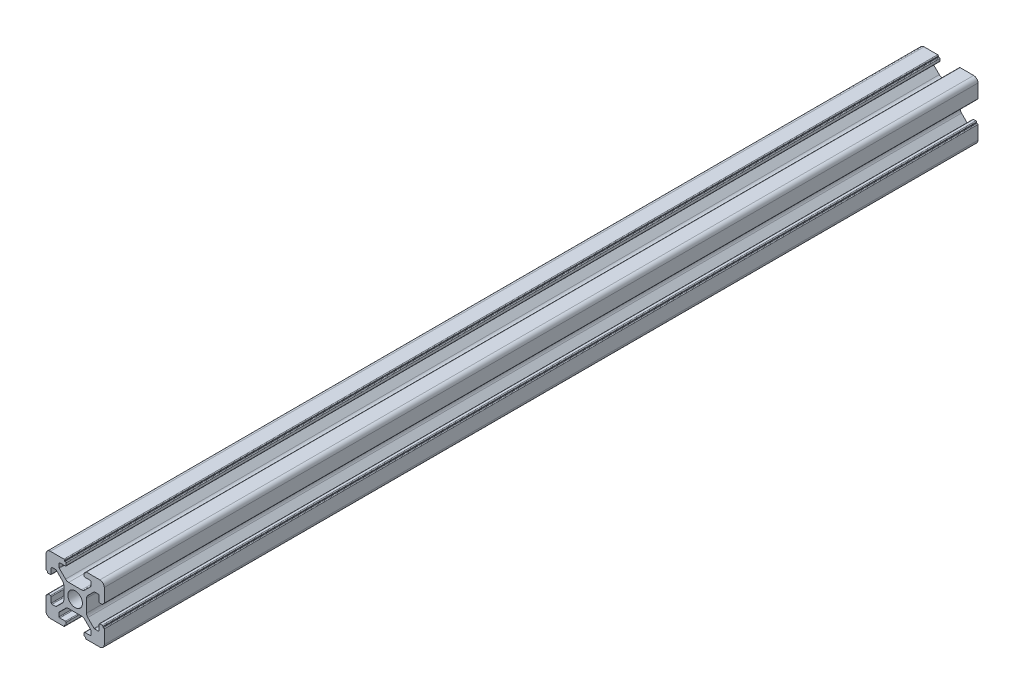
from build123d import *

# Parameters (mm, degrees)
SKETCH_1_R      = 2.5
EXTRUDE_1_DEPTH = 300


with BuildPart() as part:
    # 草图1 → 凸台-拉伸1 (new body)
    with BuildSketch(Plane.XY):
        with BuildLine():
            Line((-8.502261885, -10.002261885), (-3.85, -10.002261885))
            ThreePointArc((-3.85, -10.002261885), (-3.673223305, -9.929038581), (-3.6, -9.752261885))
            Line((-3.6, -9.752261885), (-3.6, -9.502261885))
            Line((-3.6, -9.502261885), (-3.35, -9.502261885))
            ThreePointArc((-3.35, -9.502261885), (-3.173223305, -9.429038581), (-3.1, -9.252261885))
            Line((-3.1, -9.252261885), (-3.1, -8.45))
            ThreePointArc((-3.1, -8.45), (-3.173223305, -8.273223305), (-3.35, -8.2))
            Line((-3.35, -8.2), (-5.25, -8.2))
            ThreePointArc((-5.25, -8.2), (-5.426776695, -8.126776695), (-5.5, -7.95))
            Line((-5.5, -7.95), (-5.5, -6.664213562))
            ThreePointArc((-5.5, -6.664213562), (-5.480969883, -6.568542704), (-5.426776695, -6.487436867))
            Line((-5.426776695, -6.487436867), (-3.278679656, -4.339339828))
            ThreePointArc((-3.278679656, -4.339339828), (-2.792044633, -4.014180701), (-2.218019485, -3.9))
            Line((-2.218019485, -3.9), (2.218019485, -3.9))
            ThreePointArc((2.218019485, -3.9), (2.792044633, -4.014180701), (3.278679656, -4.339339828))
            Line((3.278679656, -4.339339828), (5.426776695, -6.487436867))
            ThreePointArc((5.426776695, -6.487436867), (5.480969883, -6.568542704), (5.5, -6.664213562))
            Line((5.5, -6.664213562), (5.5, -7.95))
            ThreePointArc((5.5, -7.95), (5.426776695, -8.126776695), (5.25, -8.2))
            Line((5.25, -8.2), (3.35, -8.2))
            ThreePointArc((3.35, -8.2), (3.173223305, -8.273223305), (3.1, -8.45))
            Line((3.1, -8.45), (3.1, -9.252261885))
            ThreePointArc((3.1, -9.252261885), (3.173223305, -9.429038581), (3.35, -9.502261885))
            Line((3.35, -9.502261885), (3.6, -9.502261885))
            Line((3.6, -9.502261885), (3.6, -9.752261885))
            ThreePointArc((3.6, -9.752261885), (3.673223305, -9.929038581), (3.85, -10.002261885))
            Line((3.85, -10.002261885), (8.502261885, -10.002261885))
            ThreePointArc((8.502261885, -10.002261885), (9.562922057, -9.562922057), (10.002261885, -8.502261885))
            Line((10.002261885, -8.502261885), (10.002261885, -3.85))
            ThreePointArc((10.002261885, -3.85), (9.929038581, -3.673223305), (9.752261885, -3.6))
            Line((9.752261885, -3.6), (9.502261885, -3.6))
            Line((9.502261885, -3.6), (9.502261885, -3.35))
            ThreePointArc((9.502261885, -3.35), (9.429038581, -3.173223305), (9.252261885, -3.1))
            Line((9.252261885, -3.1), (8.45, -3.1))
            ThreePointArc((8.45, -3.1), (8.273223305, -3.173223305), (8.2, -3.35))
            Line((8.2, -3.35), (8.2, -5.25))
            ThreePointArc((8.2, -5.25), (8.126776695, -5.426776695), (7.95, -5.5))
            Line((7.95, -5.5), (6.664213562, -5.5))
            ThreePointArc((6.664213562, -5.5), (6.568542704, -5.480969883), (6.487436867, -5.426776695))
            Line((6.487436867, -5.426776695), (4.339339828, -3.278679656))
            ThreePointArc((4.339339828, -3.278679656), (4.014180701, -2.792044633), (3.9, -2.218019485))
            Line((3.9, -2.218019485), (3.9, 2.218019485))
            ThreePointArc((3.9, 2.218019485), (4.014180701, 2.792044633), (4.339339828, 3.278679656))
            Line((4.339339828, 3.278679656), (6.487436867, 5.426776695))
            ThreePointArc((6.487436867, 5.426776695), (6.568542704, 5.480969883), (6.664213562, 5.5))
            Line((6.664213562, 5.5), (7.95, 5.5))
            ThreePointArc((7.95, 5.5), (8.126776695, 5.426776695), (8.2, 5.25))
            Line((8.2, 5.25), (8.2, 3.35))
            ThreePointArc((8.2, 3.35), (8.273223305, 3.173223305), (8.45, 3.1))
            Line((8.45, 3.1), (9.252261885, 3.1))
            ThreePointArc((9.252261885, 3.1), (9.429038581, 3.173223305), (9.502261885, 3.35))
            Line((9.502261885, 3.35), (9.502261885, 3.6))
            Line((9.502261885, 3.6), (9.752261885, 3.6))
            ThreePointArc((9.752261885, 3.6), (9.929038581, 3.673223305), (10.002261885, 3.85))
            Line((10.002261885, 3.85), (10.002261885, 8.502261885))
            ThreePointArc((10.002261885, 8.502261885), (9.562922057, 9.562922057), (8.502261885, 10.002261885))
            Line((8.502261885, 10.002261885), (3.85, 10.002261885))
            ThreePointArc((3.85, 10.002261885), (3.673223305, 9.929038581), (3.6, 9.752261885))
            Line((3.6, 9.752261885), (3.6, 9.502261885))
            Line((3.6, 9.502261885), (3.35, 9.502261885))
            ThreePointArc((3.35, 9.502261885), (3.173223305, 9.429038581), (3.1, 9.252261885))
            Line((3.1, 9.252261885), (3.1, 8.45))
            ThreePointArc((3.1, 8.45), (3.173223305, 8.273223305), (3.35, 8.2))
            Line((3.35, 8.2), (5.25, 8.2))
            ThreePointArc((5.25, 8.2), (5.426776695, 8.126776695), (5.5, 7.95))
            Line((5.5, 7.95), (5.5, 6.664213562))
            ThreePointArc((5.5, 6.664213562), (5.480969883, 6.568542704), (5.426776695, 6.487436867))
            Line((5.426776695, 6.487436867), (3.278679656, 4.339339828))
            ThreePointArc((3.278679656, 4.339339828), (2.792044633, 4.014180701), (2.218019485, 3.9))
            Line((2.218019485, 3.9), (-2.218019485, 3.9))
            ThreePointArc((-2.218019485, 3.9), (-2.792044633, 4.014180701), (-3.278679656, 4.339339828))
            Line((-3.278679656, 4.339339828), (-5.426776695, 6.487436867))
            ThreePointArc((-5.426776695, 6.487436867), (-5.480969883, 6.568542704), (-5.5, 6.664213562))
            Line((-5.5, 6.664213562), (-5.5, 7.95))
            ThreePointArc((-5.5, 7.95), (-5.426776695, 8.126776695), (-5.25, 8.2))
            Line((-5.25, 8.2), (-3.35, 8.2))
            ThreePointArc((-3.35, 8.2), (-3.173223305, 8.273223305), (-3.1, 8.45))
            Line((-3.1, 8.45), (-3.1, 9.252261885))
            ThreePointArc((-3.1, 9.252261885), (-3.173223305, 9.429038581), (-3.35, 9.502261885))
            Line((-3.35, 9.502261885), (-3.6, 9.502261885))
            Line((-3.6, 9.502261885), (-3.6, 9.752261885))
            ThreePointArc((-3.6, 9.752261885), (-3.673223305, 9.929038581), (-3.85, 10.002261885))
            Line((-3.85, 10.002261885), (-8.502261885, 10.002261885))
            ThreePointArc((-8.502261885, 10.002261885), (-9.562922057, 9.562922057), (-10.002261885, 8.502261885))
            Line((-10.002261885, 8.502261885), (-10.002261885, 3.85))
            ThreePointArc((-10.002261885, 3.85), (-9.929038581, 3.673223305), (-9.752261885, 3.6))
            Line((-9.752261885, 3.6), (-9.502261885, 3.6))
            Line((-9.502261885, 3.6), (-9.502261885, 3.35))
            ThreePointArc((-9.502261885, 3.35), (-9.429038581, 3.173223305), (-9.252261885, 3.1))
            Line((-9.252261885, 3.1), (-8.45, 3.1))
            ThreePointArc((-8.45, 3.1), (-8.273223305, 3.173223305), (-8.2, 3.35))
            Line((-8.2, 3.35), (-8.2, 5.25))
            ThreePointArc((-8.2, 5.25), (-8.126776695, 5.426776695), (-7.95, 5.5))
            Line((-7.95, 5.5), (-6.664213562, 5.5))
            ThreePointArc((-6.664213562, 5.5), (-6.568542704, 5.480969883), (-6.487436867, 5.426776695))
            Line((-6.487436867, 5.426776695), (-4.339339828, 3.278679656))
            ThreePointArc((-4.339339828, 3.278679656), (-4.014180701, 2.792044633), (-3.9, 2.218019485))
            Line((-3.9, 2.218019485), (-3.9, -2.218019485))
            ThreePointArc((-3.9, -2.218019485), (-4.014180701, -2.792044633), (-4.339339828, -3.278679656))
            Line((-4.339339828, -3.278679656), (-6.487436867, -5.426776695))
            ThreePointArc((-6.487436867, -5.426776695), (-6.568542704, -5.480969883), (-6.664213562, -5.5))
            Line((-6.664213562, -5.5), (-7.95, -5.5))
            ThreePointArc((-7.95, -5.5), (-8.126776695, -5.426776695), (-8.2, -5.25))
            Line((-8.2, -5.25), (-8.2, -3.35))
            ThreePointArc((-8.2, -3.35), (-8.273223305, -3.173223305), (-8.45, -3.1))
            Line((-8.45, -3.1), (-9.252261885, -3.1))
            ThreePointArc((-9.252261885, -3.1), (-9.429038581, -3.173223305), (-9.502261885, -3.35))
            Line((-9.502261885, -3.35), (-9.502261885, -3.6))
            Line((-9.502261885, -3.6), (-9.752261885, -3.6))
            ThreePointArc((-9.752261885, -3.6), (-9.929038581, -3.673223305), (-10.002261885, -3.85))
            Line((-10.002261885, -3.85), (-10.002261885, -8.502261885))
            ThreePointArc((-10.002261885, -8.502261885), (-9.562922057, -9.562922057), (-8.502261885, -10.002261885))
        make_face()
        Circle(SKETCH_1_R, mode=Mode.SUBTRACT)
    extrude(amount=EXTRUDE_1_DEPTH)


solid = part.part
